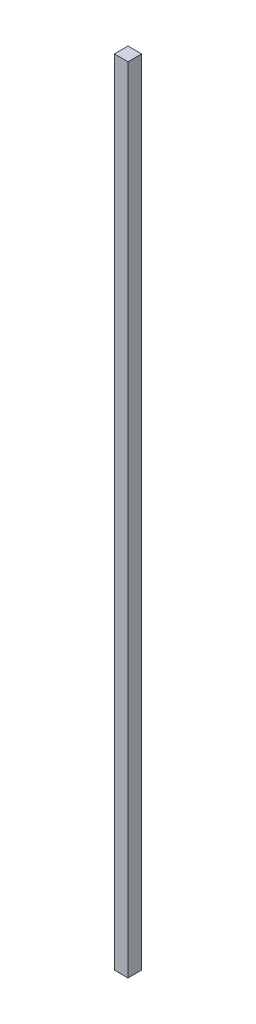
from build123d import *

# Parameters (mm, degrees)
ESBO_O2_W                = 50
ESBO_O2_H                = 50
RESSALTO_EXTRUS_O1_DEPTH = 2900


with BuildPart() as part:
    # Esboço2 → Ressalto-extrusão1 (new body)
    with BuildSketch(Plane(origin=(0, 0, 0), x_dir=(1, 0, 0), z_dir=(0, 1, 0))):
        with Locations((-25, 4.076086957)):
            Rectangle(ESBO_O2_W, ESBO_O2_H)
    extrude(amount=RESSALTO_EXTRUS_O1_DEPTH)


solid = part.part
